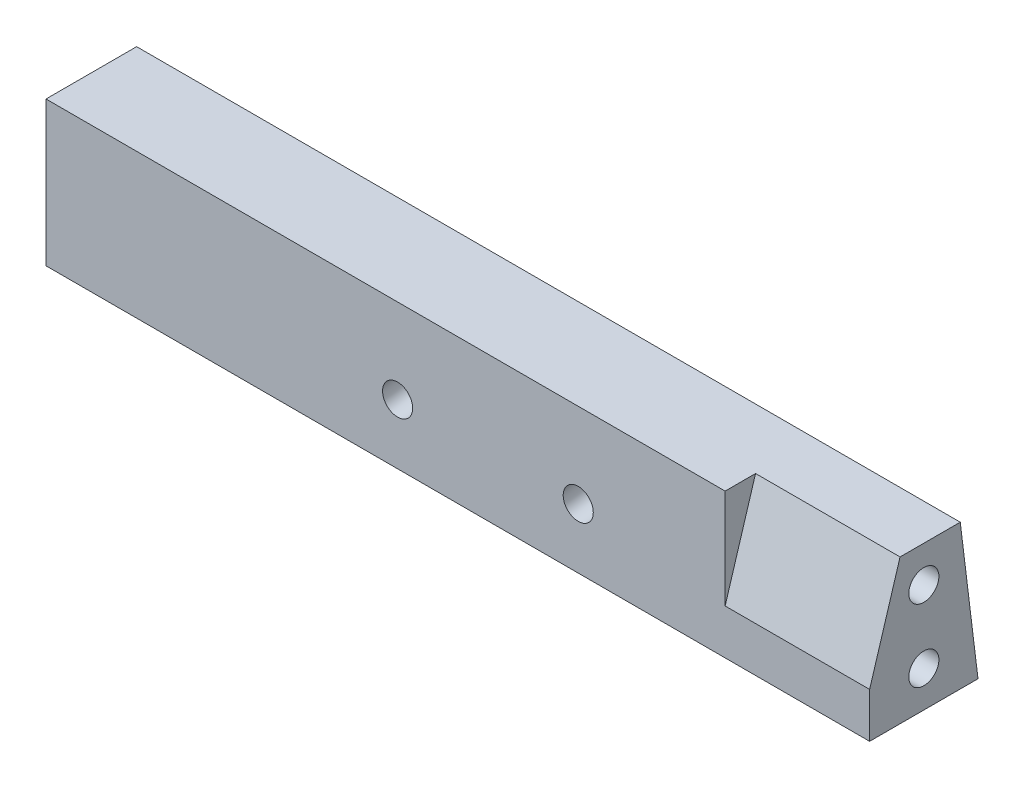
from build123d import *

# Parameters (mm, degrees)
RESSALTO_EXTRUS_O1_DEPTH      = 68.4
CORTE_EXTRUS_O1_DEPTH         = 12
FURO_ROSCADO_DE_M3X0_51_D     = 2.5
FURO_ROSCADO_DE_M3X0_51_DEPTH = 8.5
FURO_ROSCADO_DE_M3X0_51_TIP   = 0.751075774
FURO_ROSCADO_DE_M3X0_52_D     = 2.5
FURO_ROSCADO_DE_M3X0_52_DEPTH = 8.5
FURO_ROSCADO_DE_M3X0_52_TIP   = 0.751075774
FURO_ROSCADO_DE_M3X0_53_D     = 2.5


with BuildPart() as part:
    # Esboço1 → Ressalto-extrusão1 (new body)
    with BuildSketch(Plane(origin=(0, 0, 0), x_dir=(0, 0, -1), z_dir=(1, 0, 0))):
        Polygon((-4.5, -6), (4.5, -6), (3.026585269, 6), (-4.5, 6), align=None)
    extrude(amount=RESSALTO_EXTRUS_O1_DEPTH)

    # Esboço2 → Corte-extrusão1 (cut)
    with BuildSketch(Plane(origin=(68.4, 0, 0), x_dir=(0, 0, -1), z_dir=(1, 0, 0))):
        Polygon((-1.973414731, 6), (-4.5, -2.264088043), (-4.5, 6), align=None)
    extrude(amount=-CORTE_EXTRUS_O1_DEPTH, mode=Mode.SUBTRACT)

    # Furo roscado de M3x0.51
    with Locations(Plane(origin=(68.4, 0, 0), x_dir=(0, 0, -1), z_dir=(1, 0, 0))):
        with Locations((0, -3), (0, 3)):
            Hole(FURO_ROSCADO_DE_M3X0_51_D / 2, depth=FURO_ROSCADO_DE_M3X0_51_DEPTH)
            with Locations((0, 0, -(FURO_ROSCADO_DE_M3X0_51_DEPTH + FURO_ROSCADO_DE_M3X0_51_TIP / 2))):  # 118° drill point
                Cone(0, FURO_ROSCADO_DE_M3X0_51_D / 2, FURO_ROSCADO_DE_M3X0_51_TIP, mode=Mode.SUBTRACT)

    # Furo roscado de M3x0.52
    with Locations(Plane.ZY):
        with Locations((0, 3), (0, -3)):
            Hole(FURO_ROSCADO_DE_M3X0_52_D / 2, depth=FURO_ROSCADO_DE_M3X0_52_DEPTH)
            with Locations((0, 0, -(FURO_ROSCADO_DE_M3X0_52_DEPTH + FURO_ROSCADO_DE_M3X0_52_TIP / 2))):  # 118° drill point
                Cone(0, FURO_ROSCADO_DE_M3X0_52_D / 2, FURO_ROSCADO_DE_M3X0_52_TIP, mode=Mode.SUBTRACT)

    # Furo roscado de M3x0.53 (through all)
    with Locations(Plane(origin=(0, 0.455211444, -3.707399697), x_dir=(-1, 0, 0), z_dir=(0, 0.121869343, -0.992546152))):
        with Locations((-29.2, -0.464432322), (-44.2, -0.464432322)):
            Hole(FURO_ROSCADO_DE_M3X0_53_D / 2)


solid = part.part
